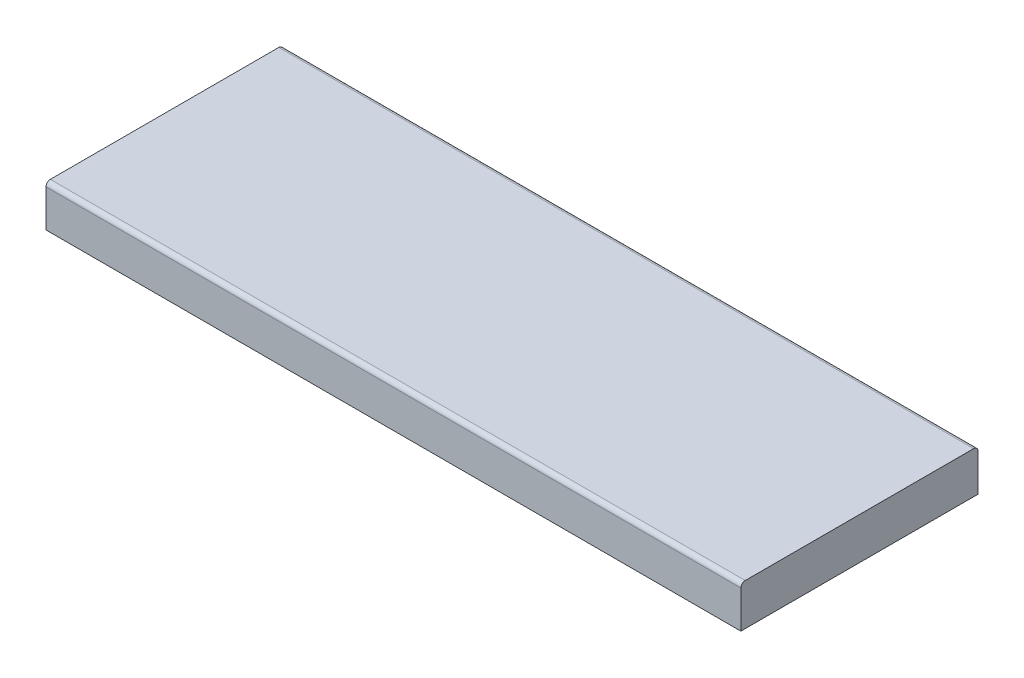
from build123d import *

# Parameters (mm, degrees)
SKETCH1_W           = 160
SKETCH1_H           = 54.6
BOSS_EXTRUDE1_DEPTH = 9.6
FILLET1_R           = 1


with BuildPart() as part:
    # Sketch1 → Boss-Extrude1 (new body)
    with BuildSketch(Plane(origin=(0, 0, 0), x_dir=(1, 0, 0), z_dir=(0, 1, 0))):
        Rectangle(SKETCH1_W, SKETCH1_H)
    extrude(amount=BOSS_EXTRUDE1_DEPTH)

    # Fillet1
    fillet1_edges = [part.edges().sort_by_distance(p)[0] for p in [
        (0, 9.6, 27.3),
        (0, 9.6, -27.3),
    ]]
    fillet(fillet1_edges, radius=FILLET1_R)


solid = part.part
